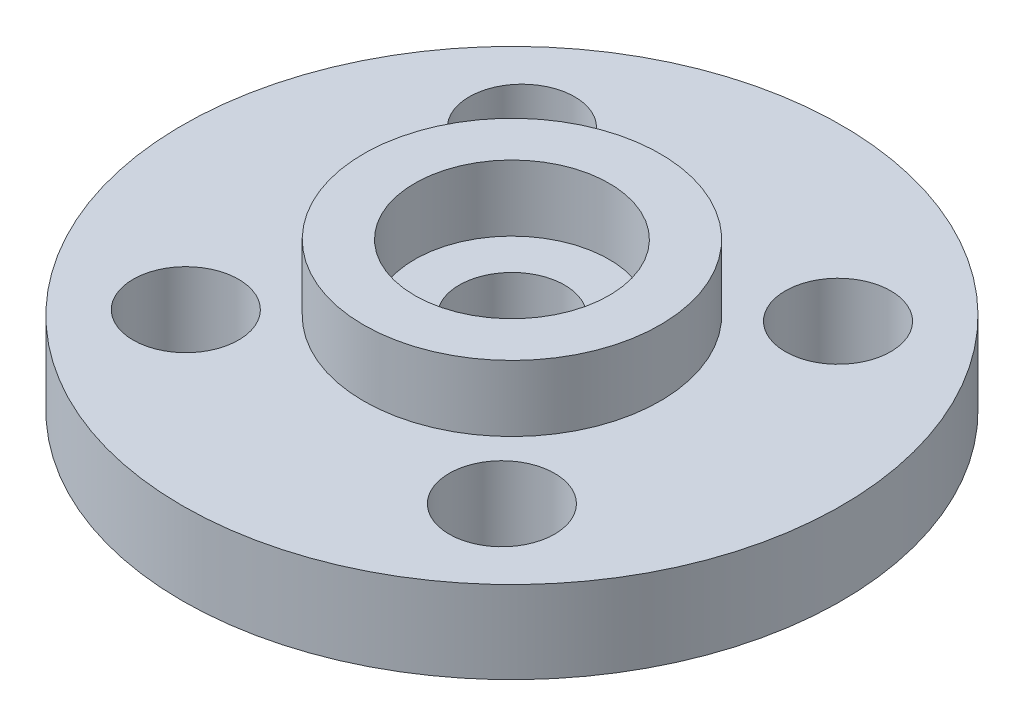
from build123d import *

# Parameters (mm, degrees)
SKETCH_1_R          = 10
EXTRUDE_1_DEPTH     = 2.5
SKETCH_3_R          = 1.6
CUT_EXTRUDE_1_DEPTH = 3.5
SKETCH_4_R          = 4.5
EXTRUDE_2_DEPTH     = 2
SKETCH_5_R          = 2.95
CUT_EXTRUDE_2_DEPTH = 2


with BuildPart() as part:
    # 草图1 → 凸台-拉伸1 (new body)
    with BuildSketch(Plane(origin=(0, 0, 0), x_dir=(1, 0, 0), z_dir=(0, 1, 0))):
        Circle(SKETCH_1_R)
    extrude(amount=EXTRUDE_1_DEPTH)

    # 草图3 → 切除-拉伸1 (cut, through all)
    with BuildSketch(Plane(origin=(0, 2.5, 0), x_dir=(1, 0, 0), z_dir=(0, 1, 0))):
        with Locations((-4.795236977, 5.099578643)):
            Circle(SKETCH_3_R)
        with Locations((-5.099578643, -4.795236977)):
            Circle(SKETCH_3_R)
        with Locations((4.795236977, -5.099578643)):
            Circle(SKETCH_3_R)
        with Locations((5.099578643, 4.795236977)):
            Circle(SKETCH_3_R)
        Circle(SKETCH_3_R)
    extrude(amount=-CUT_EXTRUDE_1_DEPTH, mode=Mode.SUBTRACT)

    # 草图4 → 凸台-拉伸2 (add)
    with BuildSketch(Plane(origin=(0, 2.5, 0), x_dir=(1, 0, 0), z_dir=(0, 1, 0))):
        Circle(SKETCH_4_R)
    extrude(amount=EXTRUDE_2_DEPTH)

    # 草图5 → 切除-拉伸2 (cut)
    with BuildSketch(Plane(origin=(0, 4.5, 0), x_dir=(1, 0, 0), z_dir=(0, 1, 0))):
        Circle(SKETCH_5_R)
    extrude(amount=-CUT_EXTRUDE_2_DEPTH, mode=Mode.SUBTRACT)


solid = part.part
